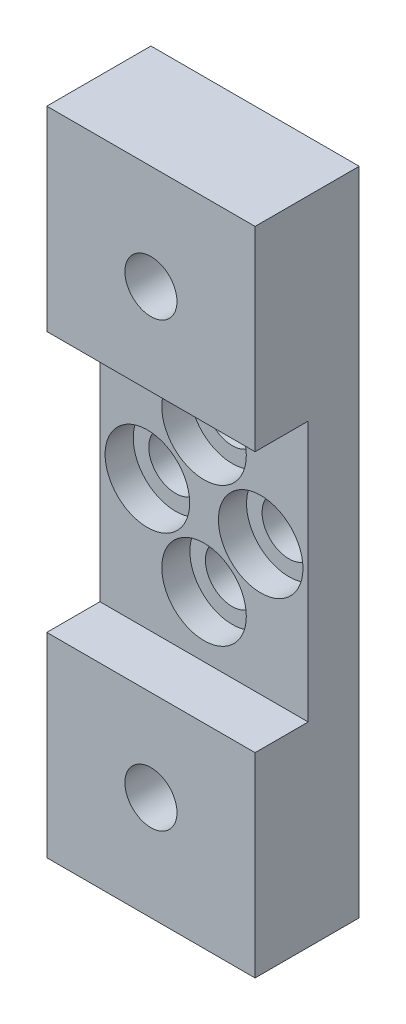
from build123d import *

# Parameters (mm, degrees)
SKETCH1_W          = 25.4
SKETCH1_H          = 79.375
EXTRUDE1_DEPTH     = 12.7
SKETCH2_W          = 25.4
SKETCH2_H          = 31.7754
CUT_EXTRUDE1_DEPTH = 6.477
SKETCH3_R          = 3.175
CUT_EXTRUDE2_DEPTH = 13.7
SKETCH4_R          = 5.1562
CUT_EXTRUDE3_DEPTH = 3.429


with BuildPart() as part:
    # Sketch1 → Extrude1 (new body)
    with BuildSketch(Plane.XY):
        with Locations((-17.074536082, 2.059865407)):
            Rectangle(SKETCH1_W, SKETCH1_H)
    extrude(amount=EXTRUDE1_DEPTH)

    # Sketch2 → Cut-Extrude1 (cut)
    with BuildSketch(Plane.XY.offset(12.7)):
        with Locations((-17.074536082, 2.059865407)):
            Rectangle(SKETCH2_W, SKETCH2_H)
    extrude(amount=-CUT_EXTRUDE1_DEPTH, mode=Mode.SUBTRACT)

    # Sketch3 → Cut-Extrude2 (cut, through all)
    with BuildSketch(Plane.XY.offset(12.7)):
        with BuildLine():
            ThreePointArc((-13.810636082, 10.556165407), (-17.074536082, 13.820065407), (-20.338436082, 10.556165407))
            Line((-20.338436082, 10.556165407), (-13.810636082, 10.556165407))
        make_face()
        with BuildLine():
            Line((-13.810636082, 10.556165407), (-20.338436082, 10.556165407))
            ThreePointArc((-20.338436082, 10.556165407), (-17.074536082, 7.292265407), (-13.810636082, 10.556165407))
        make_face()
        with BuildLine():
            ThreePointArc((-23.983336082, 5.323765407), (-26.291261906, 4.36779123), (-27.247236082, 2.059865407))
            Line((-27.247236082, 2.059865407), (-23.983336082, 2.059865407))
            Line((-23.983336082, 2.059865407), (-23.983336082, 5.323765407))
        make_face()
        with BuildLine():
            Line((-23.983336082, 2.059865407), (-27.247236082, 2.059865407))
            ThreePointArc((-27.247236082, 2.059865407), (-26.291261906, -0.248060416), (-23.983336082, -1.204034593))
            Line((-23.983336082, -1.204034593), (-23.983336082, 2.059865407))
        make_face()
        with BuildLine():
            Line((-23.983336082, 5.323765407), (-23.983336082, 2.059865407))
            Line((-23.983336082, 2.059865407), (-20.719436082, 2.059865407))
            ThreePointArc((-20.719436082, 2.059865407), (-21.675410259, 4.36779123), (-23.983336082, 5.323765407))
        make_face()
        with BuildLine():
            Line((-20.719436082, 2.059865407), (-23.983336082, 2.059865407))
            Line((-23.983336082, 2.059865407), (-23.983336082, -1.204034593))
            ThreePointArc((-23.983336082, -1.204034593), (-21.675410259, -0.248060416), (-20.719436082, 2.059865407))
        make_face()
        with BuildLine():
            ThreePointArc((-10.165736082, 5.323765407), (-12.473661906, 4.36779123), (-13.429636082, 2.059865407))
            Line((-13.429636082, 2.059865407), (-10.165736082, 2.059865407))
            Line((-10.165736082, 2.059865407), (-10.165736082, 5.323765407))
        make_face()
        with BuildLine():
            Line((-10.165736082, 2.059865407), (-13.429636082, 2.059865407))
            ThreePointArc((-13.429636082, 2.059865407), (-12.473661906, -0.248060416), (-10.165736082, -1.204034593))
            Line((-10.165736082, -1.204034593), (-10.165736082, 2.059865407))
        make_face()
        with BuildLine():
            Line((-10.165736082, 5.323765407), (-10.165736082, 2.059865407))
            Line((-10.165736082, 2.059865407), (-6.901836082, 2.059865407))
            ThreePointArc((-6.901836082, 2.059865407), (-7.857810259, 4.36779123), (-10.165736082, 5.323765407))
        make_face()
        with BuildLine():
            Line((-6.901836082, 2.059865407), (-10.165736082, 2.059865407))
            Line((-10.165736082, 2.059865407), (-10.165736082, -1.204034593))
            ThreePointArc((-10.165736082, -1.204034593), (-7.857810259, -0.248060416), (-6.901836082, 2.059865407))
        make_face()
        with BuildLine():
            ThreePointArc((-13.810636082, -6.436434593), (-17.074536082, -3.172534593), (-20.338436082, -6.436434593))
            Line((-20.338436082, -6.436434593), (-13.810636082, -6.436434593))
        make_face()
        with BuildLine():
            Line((-13.810636082, -6.436434593), (-20.338436082, -6.436434593))
            ThreePointArc((-20.338436082, -6.436434593), (-17.074536082, -9.700334593), (-13.810636082, -6.436434593))
        make_face()
        with Locations((-17.074536082, -24.927634593)):
            Circle(SKETCH3_R)
        with Locations((-17.074536082, 29.047365407)):
            Circle(SKETCH3_R)
    extrude(amount=-CUT_EXTRUDE2_DEPTH, mode=Mode.SUBTRACT)

    # Sketch4 → Cut-Extrude3 (cut)
    with BuildSketch(Plane.XY.offset(6.223)):
        with Locations((-17.074536082, 10.556165407)):
            Circle(SKETCH4_R)
        with Locations((-10.165736082, 2.059865407)):
            Circle(SKETCH4_R)
        with Locations((-17.074536082, -6.436434593)):
            Circle(SKETCH4_R)
        with Locations((-23.983336082, 2.059865407)):
            Circle(SKETCH4_R)
    extrude(amount=-CUT_EXTRUDE3_DEPTH, mode=Mode.SUBTRACT)


solid = part.part
